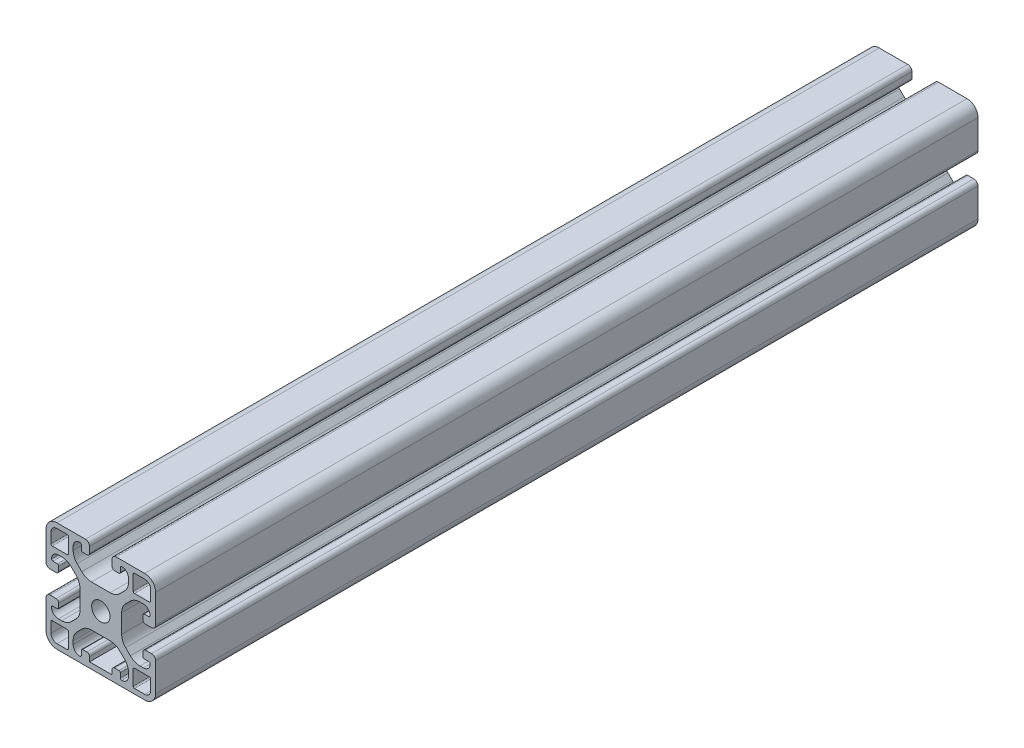
from build123d import *

# Parameters (mm, degrees)
SKIZZE1_R                       = 3.35
AUFSATZ_LINEAR_AUSTRAGEN1_DEPTH = 300


with BuildPart() as part:
    # Skizze1 → Aufsatz-Linear austragen1 (new body)
    with BuildSketch(Plane.XY.offset(1000)):
        with BuildLine():
            Line((5.899999985, 34.292388165), (5.899999985, 35.500000003))
            ThreePointArc((5.899999985, 35.500000003), (6.632233037, 37.267766961), (8.399999999, 38.000000003))
            ThreePointArc((8.399999999, 38.000000003), (8.753553388, 37.853553393), (8.899999996, 37.500000003))
            Line((8.899999996, 37.500000003), (8.899999996, 35.850000004))
            ThreePointArc((8.899999996, 35.850000004), (9.046446605, 35.496446613), (9.399999996, 35.350000004))
            Line((9.399999996, 35.350000004), (10.899999947, 35.350000004))
            ThreePointArc((10.899999947, 35.350000004), (11.607106728, 35.642893223), (11.899999947, 36.350000004))
            Line((11.899999947, 36.350000004), (11.899999947, 38.500000016))
            ThreePointArc((11.899999947, 38.500000016), (11.460660119, 39.560660188), (10.399999947, 40.000000016))
            Line((10.399999947, 40.000000016), (5.2e-08, 40.000000016))
            ThreePointArc((5.2e-08, 40.000000016), (-2.828427117, 38.828427123), (-4.000000011, 35.999999954))
            Line((-4.000000011, 35.999999954), (-4.000000011, 25.599999996))
            ThreePointArc((-4.000000011, 25.599999996), (-3.560660183, 24.539339825), (-2.500000012, 24.099999997))
            Line((-2.500000012, 24.099999997), (-0.350000011, 24.099999997))
            ThreePointArc((-0.350000011, 24.099999997), (0.35710677, 24.392893216), (0.649999989, 25.099999997))
            Line((0.649999989, 25.099999997), (0.649999989, 26.599999997))
            ThreePointArc((0.649999989, 26.599999997), (0.50355338, 26.953553387), (0.149999989, 27.099999997))
            Line((0.149999989, 27.099999997), (-1.500000011, 27.099999997))
            ThreePointArc((-1.500000011, 27.099999997), (-1.853553401, 27.246446605), (-2.000000011, 27.599999993))
            ThreePointArc((-2.000000011, 27.599999993), (-1.26776697, 29.367766957), (0.499999989, 30.10000001))
            Line((0.499999989, 30.10000001), (1.707611833, 30.10000001))
            ThreePointArc((1.707611833, 30.10000001), (3.621028995, 29.719397673), (5.243145739, 28.635533916))
            Line((5.243145739, 28.635533916), (6.935533894, 26.943145761))
            ThreePointArc((6.935533894, 26.943145761), (8.01939765, 25.321029017), (8.399999988, 23.407611855))
            Line((8.399999988, 23.407611855), (8.399999988, 16.592388122))
            ThreePointArc((8.399999988, 16.592388122), (8.01939765, 14.678970961), (6.935533894, 13.056854217))
            Line((6.935533894, 13.056854217), (5.243145737, 11.36446606))
            ThreePointArc((5.243145737, 11.36446606), (3.621028993, 10.280602303), (1.707611831, 9.899999966))
            Line((1.707611831, 9.899999966), (0.49999999, 9.899999966))
            ThreePointArc((0.49999999, 9.899999966), (-1.267766968, 10.632233018), (-2.00000001, 12.399999979))
            ThreePointArc((-2.00000001, 12.399999979), (-1.8535534, 12.753553368), (-1.50000001, 12.899999977))
            Line((-1.50000001, 12.899999977), (0.149999989, 12.899999977))
            ThreePointArc((0.149999989, 12.899999977), (0.50355338, 13.046446586), (0.649999989, 13.399999977))
            Line((0.649999989, 13.399999977), (0.649999989, 14.899999976))
            ThreePointArc((0.649999989, 14.899999976), (0.35710677, 15.607106757), (-0.350000011, 15.899999976))
            Line((-0.350000011, 15.899999976), (-2.50000001, 15.899999976))
            ThreePointArc((-2.50000001, 15.899999976), (-3.560660182, 15.460660148), (-4.000000011, 14.399999976))
            Line((-4.000000011, 14.399999976), (-4.000000011, 4.000000069))
            ThreePointArc((-4.000000011, 4.000000069), (-2.828427121, 1.171572909), (4e-08, 1.9e-08))
            Line((4e-08, 1.9e-08), (31.999999925, 1.9e-08))
            ThreePointArc((31.999999925, 1.9e-08), (34.828427086, 1.171572909), (35.999999976, 4.00000007))
            Line((35.999999976, 4.00000007), (35.999999976, 14.399999977))
            ThreePointArc((35.999999976, 14.399999977), (35.560660149, 15.460660148), (34.499999978, 15.899999976))
            Line((34.499999978, 15.899999976), (32.349999991, 15.899999976))
            ThreePointArc((32.349999991, 15.899999976), (31.642893209, 15.607106757), (31.34999999, 14.899999976))
            Line((31.34999999, 14.899999976), (31.34999999, 13.399999977))
            ThreePointArc((31.34999999, 13.399999977), (31.4964466, 13.046446586), (31.84999999, 12.899999977))
            Line((31.84999999, 12.899999977), (33.499999991, 12.899999977))
            ThreePointArc((33.499999991, 12.899999977), (33.853553381, 12.753553368), (33.999999991, 12.399999979))
            ThreePointArc((33.999999991, 12.399999979), (33.267766949, 10.632233018), (31.499999991, 9.899999966))
            Line((31.499999991, 9.899999966), (30.292388185, 9.899999966))
            ThreePointArc((30.292388185, 9.899999966), (28.378971023, 10.280602303), (26.756854279, 11.36446606))
            Line((26.756854279, 11.36446606), (25.064466082, 13.056854257))
            ThreePointArc((25.064466082, 13.056854257), (23.980602325, 14.678971001), (23.599999988, 16.592388163))
            Line((23.599999988, 16.592388163), (23.599999988, 23.407611842))
            ThreePointArc((23.599999988, 23.407611842), (23.980602325, 25.321029004), (25.064466082, 26.943145747))
            Line((25.064466082, 26.943145747), (26.75685425, 28.635533916))
            ThreePointArc((26.75685425, 28.635533916), (28.378970995, 29.719397673), (30.292388156, 30.10000001))
            Line((30.292388156, 30.10000001), (31.499999989, 30.10000001))
            ThreePointArc((31.499999989, 30.10000001), (33.267766948, 29.367766957), (33.999999989, 27.599999993))
            ThreePointArc((33.999999989, 27.599999993), (33.853553379, 27.246446605), (33.499999989, 27.099999997))
            Line((33.499999989, 27.099999997), (31.84999999, 27.099999997))
            ThreePointArc((31.84999999, 27.099999997), (31.4964466, 26.953553387), (31.34999999, 26.599999997))
            Line((31.34999999, 26.599999997), (31.34999999, 25.099999997))
            ThreePointArc((31.34999999, 25.099999997), (31.642893209, 24.392893216), (32.34999999, 24.099999997))
            Line((32.34999999, 24.099999997), (34.499999976, 24.099999997))
            ThreePointArc((34.499999976, 24.099999997), (35.560660148, 24.539339825), (35.999999976, 25.599999997))
            Line((35.999999976, 25.599999997), (35.999999976, 35.999999953))
            ThreePointArc((35.999999976, 35.999999953), (34.828427083, 38.828427123), (31.999999914, 40.000000016))
            Line((31.999999914, 40.000000016), (21.600000015, 40.000000016))
            ThreePointArc((21.600000015, 40.000000016), (20.539339844, 39.560660188), (20.100000016, 38.500000017))
            Line((20.100000016, 38.500000017), (20.100000016, 36.350000004))
            ThreePointArc((20.100000016, 36.350000004), (20.392893235, 35.642893223), (21.100000017, 35.350000004))
            Line((21.100000017, 35.350000004), (22.600000014, 35.350000004))
            ThreePointArc((22.600000014, 35.350000004), (22.953553405, 35.496446613), (23.100000014, 35.850000004))
            Line((23.100000014, 35.850000004), (23.100000014, 37.500000007))
            ThreePointArc((23.100000014, 37.500000007), (23.246446625, 37.8535534), (23.600000019, 38.000000007))
            ThreePointArc((23.600000019, 38.000000007), (25.367766955, 37.267766951), (26.099999992, 35.500000007))
            Line((26.099999992, 35.500000007), (26.099999992, 34.292388127))
            ThreePointArc((26.099999992, 34.292388127), (25.719397655, 32.378970966), (24.635533898, 30.756854221))
            Line((24.635533898, 30.756854221), (22.943145779, 29.064466103))
            ThreePointArc((22.943145779, 29.064466103), (21.321029035, 27.980602346), (19.407611873, 27.600000009))
            Line((19.407611873, 27.600000009), (12.592388142, 27.600000009))
            ThreePointArc((12.592388142, 27.600000009), (10.678970981, 27.980602346), (9.056854237, 29.064466102))
            Line((9.056854237, 29.064466102), (7.36446608, 30.75685426))
            ThreePointArc((7.36446608, 30.75685426), (6.280602323, 32.378971004), (5.899999985, 34.292388165))
        make_face()
        with Locations((15.999999985, 20)):
            Circle(SKIZZE1_R, mode=Mode.SUBTRACT)
        with BuildLine():
            Line((27.799999996, 32.299999708), (27.799999996, 37.700000083))
            ThreePointArc((27.799999996, 37.700000083), (27.946446591, 38.053553439), (28.299999947, 38.200000034))
            Line((28.299999947, 38.200000034), (31.999999914, 38.200000034))
            ThreePointArc((31.999999914, 38.200000034), (33.555634889, 37.555634929), (34.199999994, 35.999999953))
            Line((34.199999994, 35.999999953), (34.199999994, 32.300000046))
            ThreePointArc((34.199999994, 32.300000046), (34.053553382, 31.946446648), (33.699999983, 31.800000035))
            Line((33.699999983, 31.800000035), (28.299999669, 31.800000035))
            ThreePointArc((28.299999669, 31.800000035), (27.94644651, 31.946446549), (27.799999996, 32.299999708))
        make_face(mode=Mode.SUBTRACT)
        with BuildLine():
            Line((28.299999669, 8.199999998), (33.700000043, 8.199999998))
            ThreePointArc((33.700000043, 8.199999998), (34.053553399, 8.053553402), (34.199999994, 7.700000046))
            Line((34.199999994, 7.700000046), (34.199999994, 4.00000007))
            ThreePointArc((34.199999994, 4.00000007), (33.555634893, 2.444365103), (31.999999925, 1.800000001))
            Line((31.999999925, 1.800000001), (28.300000007, 1.800000001))
            ThreePointArc((28.300000007, 1.800000001), (27.946446609, 1.946446613), (27.799999996, 2.300000012))
            Line((27.799999996, 2.300000012), (27.799999996, 7.700000324))
            ThreePointArc((27.799999996, 7.700000324), (27.94644651, 8.053553484), (28.299999669, 8.199999998))
        make_face(mode=Mode.SUBTRACT)
        with BuildLine():
            Line((3.700000285, 31.800000035), (-1.700000077, 31.800000035))
            ThreePointArc((-1.700000077, 31.800000035), (-2.053553433, 31.94644663), (-2.200000029, 32.299999986))
            Line((-2.200000029, 32.299999986), (-2.200000029, 35.999999954))
            ThreePointArc((-2.200000029, 35.999999954), (-1.555634924, 37.555634929), (5.2e-08, 38.200000034))
            Line((5.2e-08, 38.200000034), (3.699999947, 38.200000034))
            ThreePointArc((3.699999947, 38.200000034), (4.053553346, 38.053553422), (4.199999959, 37.700000023))
            Line((4.199999959, 37.700000023), (4.199999959, 32.299999708))
            ThreePointArc((4.199999959, 32.299999708), (4.053553445, 31.946446549), (3.700000285, 31.800000035))
        make_face(mode=Mode.SUBTRACT)
        with BuildLine():
            Line((4.199999959, 7.700000324), (4.199999959, 2.299999952))
            ThreePointArc((4.199999959, 2.299999952), (4.053553363, 1.946446596), (3.700000007, 1.800000001))
            Line((3.700000007, 1.800000001), (4e-08, 1.800000001))
            ThreePointArc((4e-08, 1.800000001), (-1.555634927, 2.444365102), (-2.200000029, 4.000000069))
            Line((-2.200000029, 4.000000069), (-2.200000029, 7.699999986))
            ThreePointArc((-2.200000029, 7.699999986), (-2.053553416, 8.053553385), (-1.700000017, 8.199999998))
            Line((-1.700000017, 8.199999998), (3.700000285, 8.199999998))
            ThreePointArc((3.700000285, 8.199999998), (4.053553445, 8.053553484), (4.199999959, 7.700000324))
        make_face(mode=Mode.SUBTRACT)
        with BuildLine():
            Line((20.100000016, 2.000000008), (11.899999947, 2.000000008))
            Line((11.899999947, 2.000000008), (11.899999947, 3.649999992))
            ThreePointArc((11.899999947, 3.649999992), (11.607106728, 4.357106773), (10.899999947, 4.649999992))
            Line((10.899999947, 4.649999992), (9.399999996, 4.649999992))
            ThreePointArc((9.399999996, 4.649999992), (9.046446606, 4.503553382), (8.899999996, 4.149999992))
            Line((8.899999996, 4.149999992), (8.899999996, 2.499999991))
            ThreePointArc((8.899999996, 2.499999991), (8.753553389, 2.146446604), (8.400000003, 1.999999994))
            ThreePointArc((8.400000003, 1.999999994), (6.632233039, 2.732233035), (5.899999985, 4.499999994))
            Line((5.899999985, 4.499999994), (5.899999985, 5.707611838))
            ThreePointArc((5.899999985, 5.707611838), (6.280602323, 7.621029001), (7.36446608, 9.243145746))
            Line((7.36446608, 9.243145746), (9.056854238, 10.935533903))
            ThreePointArc((9.056854238, 10.935533903), (10.678970982, 12.01939766), (12.592388143, 12.399999997))
            Line((12.592388143, 12.399999997), (19.407611847, 12.399999997))
            ThreePointArc((19.407611847, 12.399999997), (21.321029008, 12.01939766), (22.943145752, 10.935533904))
            Line((22.943145752, 10.935533904), (24.635533898, 9.243145757))
            ThreePointArc((24.635533898, 9.243145757), (25.719397655, 7.621029013), (26.099999992, 5.707611851))
            Line((26.099999992, 5.707611851), (26.099999992, 4.499999993))
            ThreePointArc((26.099999992, 4.499999993), (25.367766954, 2.73223305), (23.600000019, 1.999999995))
            ThreePointArc((23.600000019, 1.999999995), (23.246446625, 2.146446603), (23.100000014, 2.499999995))
            Line((23.100000014, 2.499999995), (23.100000014, 4.149999994))
            ThreePointArc((23.100000014, 4.149999994), (22.953553405, 4.503553383), (22.600000016, 4.649999992))
            Line((22.600000016, 4.649999992), (21.100000017, 4.649999992))
            ThreePointArc((21.100000017, 4.649999992), (20.392893235, 4.357106773), (20.100000016, 3.649999992))
            Line((20.100000016, 3.649999992), (20.100000016, 2.000000008))
        make_face(mode=Mode.SUBTRACT)
    extrude(amount=-AUFSATZ_LINEAR_AUSTRAGEN1_DEPTH)


solid = part.part
